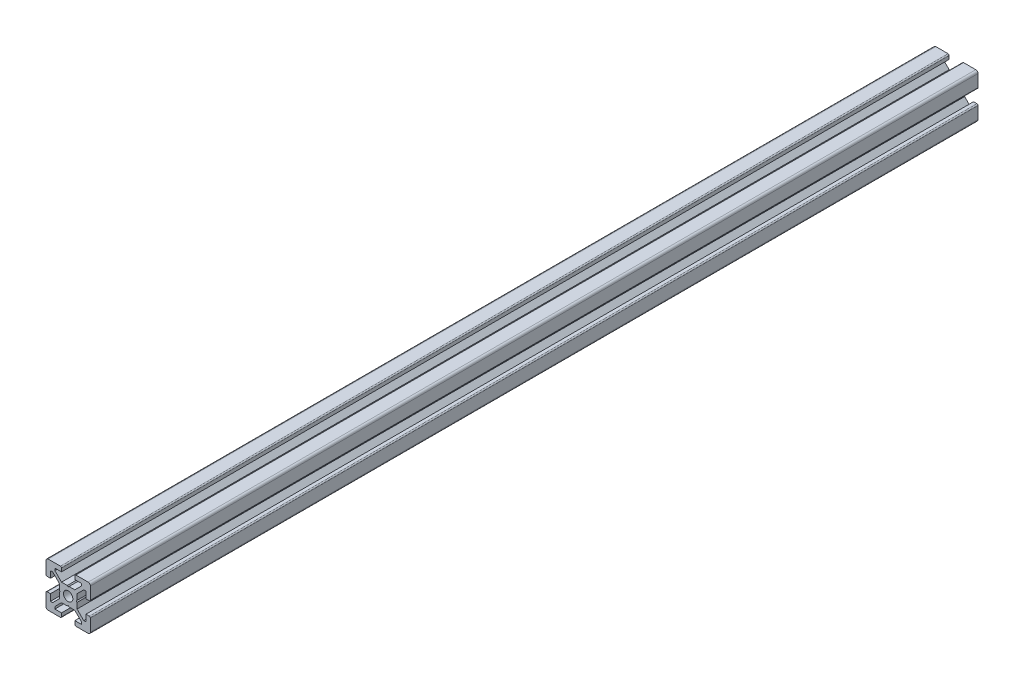
from build123d import *

# Parameters (mm, degrees)
SCHIZZO1_R                   = 2.1
ESTRUSIONE_ESTRUSIONE1_DEPTH = 400


with BuildPart() as part:
    # Schizzo1 → Estrusione-Estrusione1 (new body)
    with BuildSketch(Plane.XY):
        with BuildLine():
            Line((-3.6, 0), (-4, 0.4))
            Line((-4, 0.4), (-4, 3))
            Line((-4, 3), (-7, 6))
            Line((-7, 6), (-8, 6))
            Line((-8, 6), (-8, 3))
            Line((-8, 3), (-9.5, 3))
            ThreePointArc((-9.5, 3), (-9.853553391, 3.146446609), (-10, 3.5))
            Line((-10, 3.5), (-10, 9))
            ThreePointArc((-10, 9), (-9.707106781, 9.707106781), (-9, 10))
            Line((-9, 10), (-3.5, 10))
            ThreePointArc((-3.5, 10), (-3.146446609, 9.853553391), (-3, 9.5))
            Line((-3, 9.5), (-3, 8))
            Line((-3, 8), (-6, 8))
            Line((-6, 8), (-6, 7))
            Line((-6, 7), (-3, 4))
            Line((-3, 4), (-0.4, 4))
            Line((-0.4, 4), (0, 3.6))
            Line((0, 3.6), (0.4, 4))
            Line((0.4, 4), (3, 4))
            Line((3, 4), (6, 7))
            Line((6, 7), (6, 8))
            Line((6, 8), (3, 8))
            Line((3, 8), (3, 9.5))
            ThreePointArc((3, 9.5), (3.146446609, 9.853553391), (3.5, 10))
            Line((3.5, 10), (9, 10))
            ThreePointArc((9, 10), (9.707106781, 9.707106781), (10, 9))
            Line((10, 9), (10, 3.5))
            ThreePointArc((10, 3.5), (9.853553391, 3.146446609), (9.5, 3))
            Line((9.5, 3), (8, 3))
            Line((8, 3), (8, 6))
            Line((8, 6), (7, 6))
            Line((7, 6), (4, 3))
            Line((4, 3), (4, 0.4))
            Line((4, 0.4), (3.6, 0))
            Line((3.6, 0), (4, -0.4))
            Line((4, -0.4), (4, -3))
            Line((4, -3), (7, -6))
            Line((7, -6), (8, -6))
            Line((8, -6), (8, -3))
            Line((8, -3), (9.5, -3))
            ThreePointArc((9.5, -3), (9.853553391, -3.146446609), (10, -3.5))
            Line((10, -3.5), (10, -9))
            ThreePointArc((10, -9), (9.707106781, -9.707106781), (9, -10))
            Line((9, -10), (3.5, -10))
            ThreePointArc((3.5, -10), (3.146446609, -9.853553391), (3, -9.5))
            Line((3, -9.5), (3, -8))
            Line((3, -8), (6, -8))
            Line((6, -8), (6, -7))
            Line((6, -7), (3, -4))
            Line((3, -4), (0.4, -4))
            Line((0.4, -4), (0, -3.6))
            Line((0, -3.6), (-0.4, -4))
            Line((-0.4, -4), (-3, -4))
            Line((-3, -4), (-6, -7))
            Line((-6, -7), (-6, -8))
            Line((-6, -8), (-3, -8))
            Line((-3, -8), (-3, -9.5))
            ThreePointArc((-3, -9.5), (-3.146446609, -9.853553391), (-3.5, -10))
            Line((-3.5, -10), (-9, -10))
            ThreePointArc((-9, -10), (-9.707106781, -9.707106781), (-10, -9))
            Line((-10, -9), (-10, -3.5))
            ThreePointArc((-10, -3.5), (-9.853553391, -3.146446609), (-9.5, -3))
            Line((-9.5, -3), (-8, -3))
            Line((-8, -3), (-8, -6))
            Line((-8, -6), (-7, -6))
            Line((-7, -6), (-4, -3))
            Line((-4, -3), (-4, -0.4))
            Line((-4, -0.4), (-3.6, 0))
        make_face()
        Circle(SCHIZZO1_R, mode=Mode.SUBTRACT)
    extrude(amount=ESTRUSIONE_ESTRUSIONE1_DEPTH)


solid = part.part
